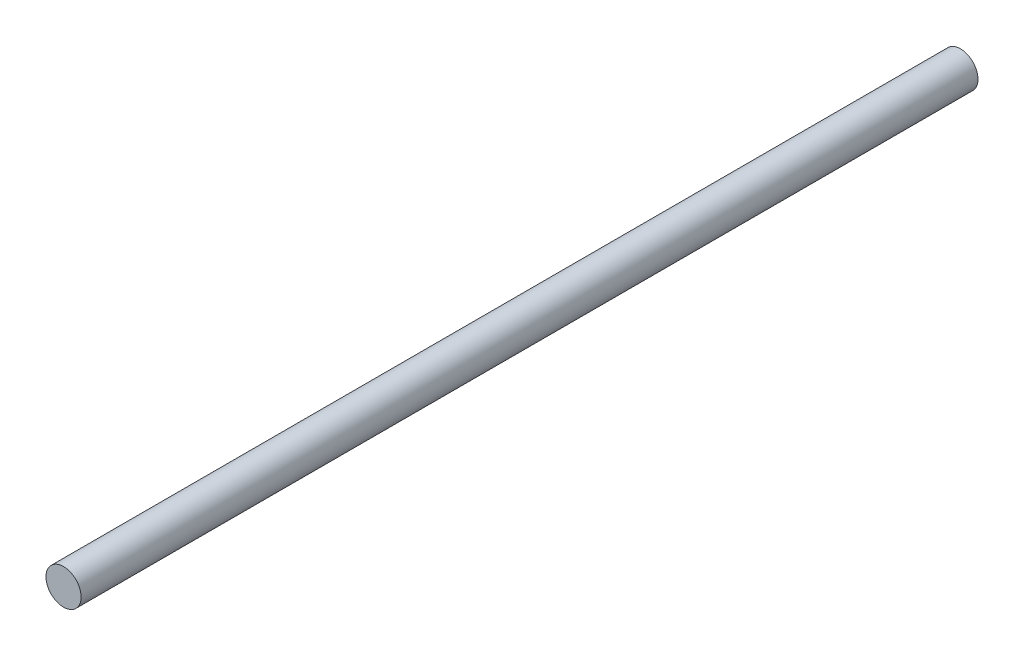
from build123d import *

# Parameters (mm, degrees)
SKETCH1_R           = 2.38125
BOSS_EXTRUDE1_DEPTH = 121.4628


with BuildPart() as part:
    # Sketch1 → Boss-Extrude1 (new body)
    with BuildSketch(Plane.XY):
        Circle(SKETCH1_R)
    extrude(amount=BOSS_EXTRUDE1_DEPTH)


solid = part.part
